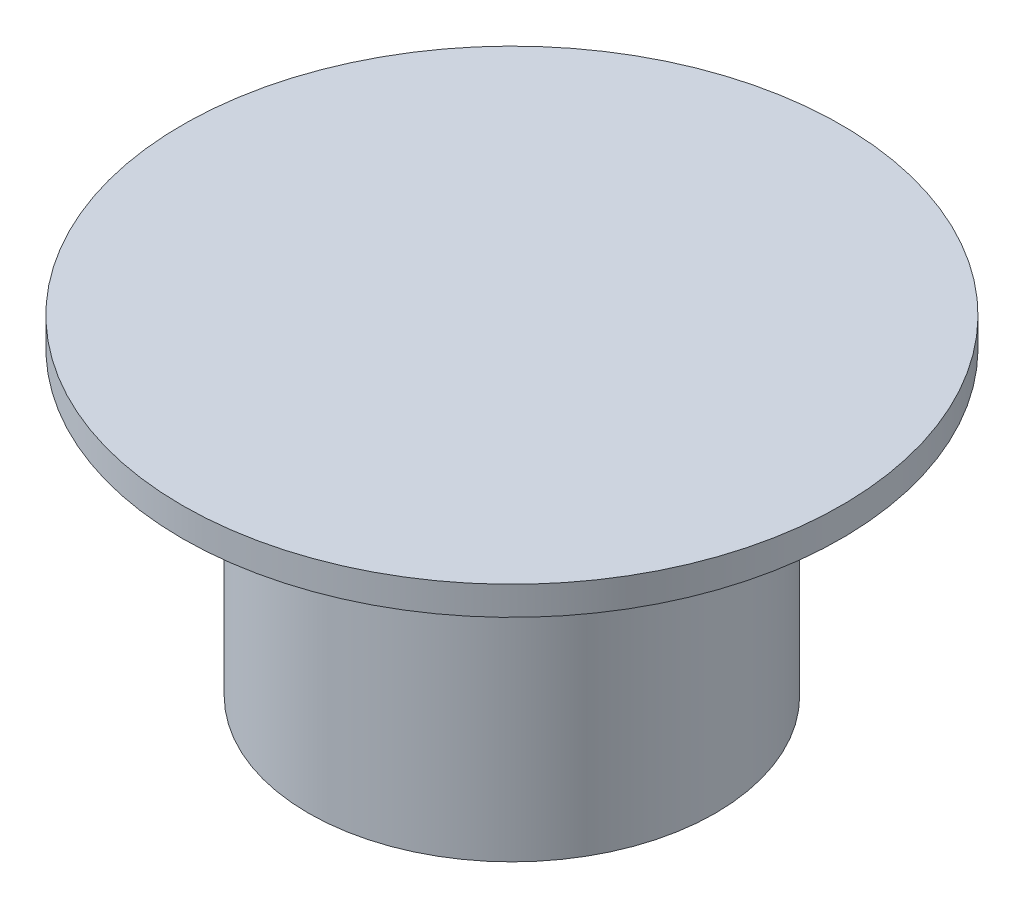
from build123d import *

# Parameters (mm, degrees)
SKETCH1_R           = 7.1
BOSS_EXTRUDE1_DEPTH = 10.5
SKETCH2_R           = 11.5
BOSS_EXTRUDE2_DEPTH = 1
SKETCH3_W           = 5
SKETCH3_H           = 3
CUT_EXTRUDE1_DEPTH  = 6


with BuildPart() as part:
    # Sketch1 → Boss-Extrude1 (new body)
    with BuildSketch(Plane(origin=(0, 0, 0), x_dir=(1, 0, 0), z_dir=(0, 1, 0))):
        Circle(SKETCH1_R)
    extrude(amount=BOSS_EXTRUDE1_DEPTH)

    # Sketch2 → Boss-Extrude2 (add)
    with BuildSketch(Plane(origin=(0, 10.5, 0), x_dir=(1, 0, 0), z_dir=(0, 1, 0))):
        Circle(SKETCH2_R)
    extrude(amount=BOSS_EXTRUDE2_DEPTH)

    # Sketch3 → Cut-Extrude1 (cut)
    with BuildSketch(Plane.XZ):
        Rectangle(SKETCH3_W, SKETCH3_H)
    extrude(amount=-CUT_EXTRUDE1_DEPTH, mode=Mode.SUBTRACT)


solid = part.part
